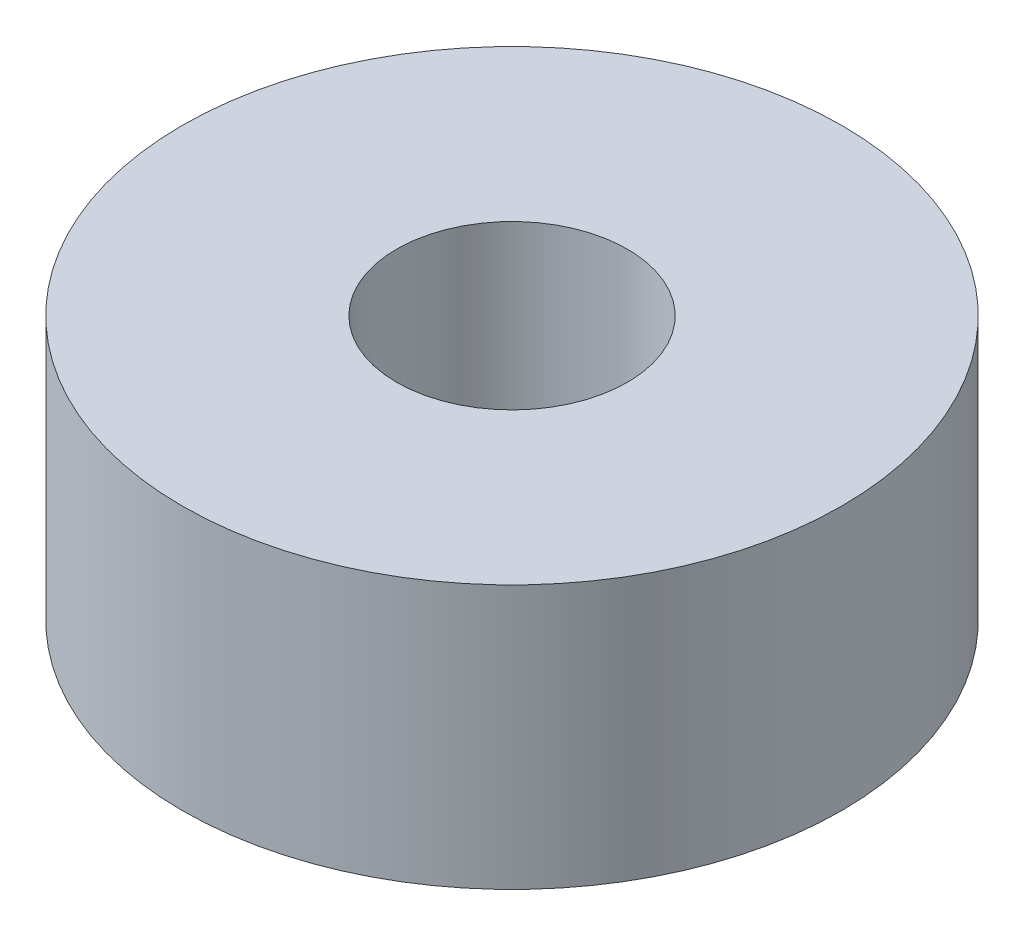
from build123d import *

# Parameters (mm, degrees)
SKETCH1_R           = 5
SKETCH1_R_2         = 1.75
BOSS_EXTRUDE1_DEPTH = 4


with BuildPart() as part:
    # Sketch1 → Boss-Extrude1 (new body)
    with BuildSketch(Plane(origin=(0, 0, 0), x_dir=(1, 0, 0), z_dir=(0, 1, 0))):
        Circle(SKETCH1_R)
        Circle(SKETCH1_R_2, mode=Mode.SUBTRACT)
    extrude(amount=BOSS_EXTRUDE1_DEPTH)


solid = part.part
